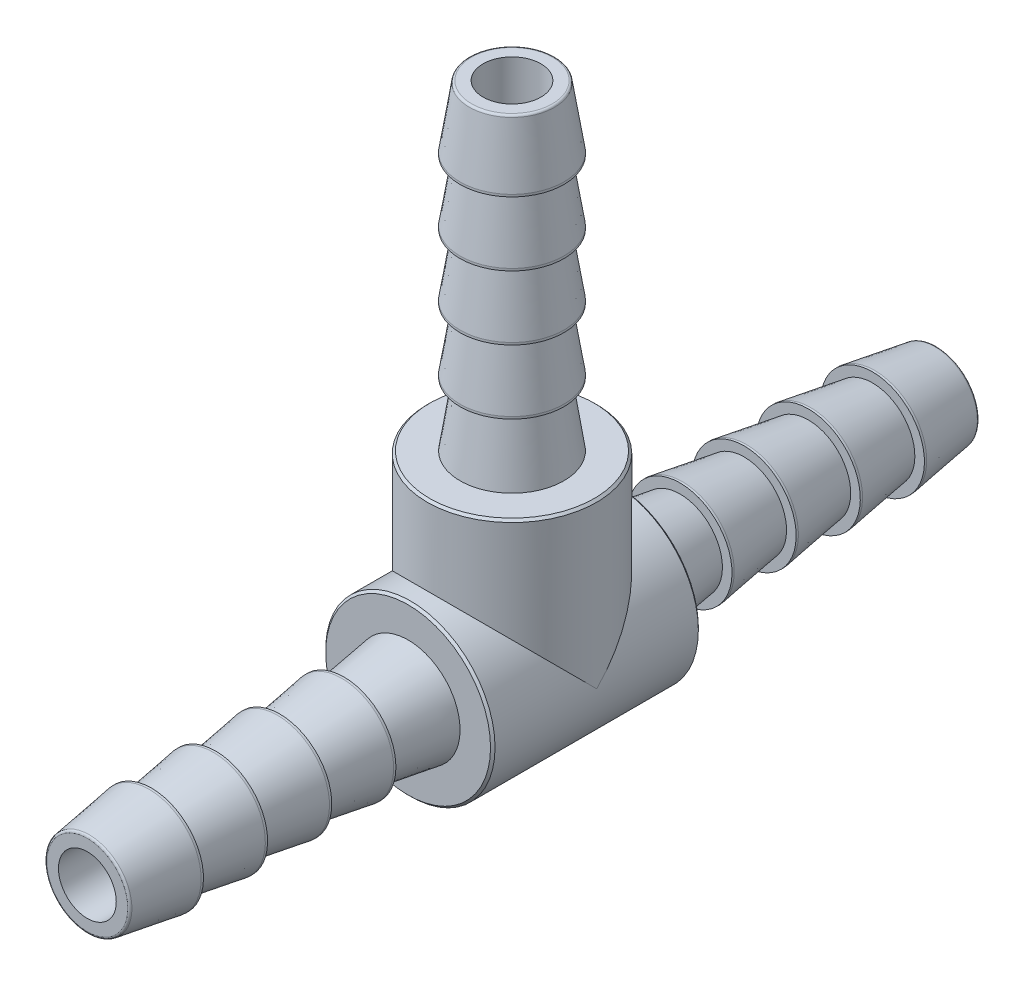
from build123d import *

# Parameters (mm, degrees)
SKETCH2_W       = 47.752
SKETCH2_H       = 4.7625
LPATTERN1_COUNT = 4
LPATTERN1_PITCH = 3.6068
SKETCH6_W       = 4.7625
SKETCH6_H       = 27.2415
LPATTERN2_COUNT = 4
LPATTERN2_PITCH = 3.6068
SKETCH9_W       = 1.6256
SKETCH9_H       = 27.2415
CHAMFER1_SIZE   = 0.127
FILLET1_R       = 0.127


with BuildPart() as part:
    # Sketch2 → Revolve1 (revolve)
    with BuildSketch(Plane(origin=(0, 0, 0), x_dir=(0, 0, -1), z_dir=(1, 0, 0)), mode=Mode.PRIVATE) as revolve1_sk:
        with Locations((0, 2.38125)):
            Rectangle(SKETCH2_W, SKETCH2_H)
    revolve(revolve1_sk.sketch.rotate(Axis((0, 0, 23.876), (0, 0, -1)), 90), axis=Axis((0, 0, 23.876), (0, 0, -1)))

    # Sketch3 → Cut-Revolve1 (revolve, cut)
    with BuildSketch(Plane(origin=(0, 0, 0), x_dir=(0, 0, -1), z_dir=(1, 0, 0)), mode=Mode.PRIVATE) as cut_revolve1_sk:
        Polygon((-23.876, 4.7625), (-23.876, 2.38125), (-9.4488, 2.38125), (-5.842, 2.921), (-5.842, 4.7625), align=None)
    cut_revolve1 = revolve(cut_revolve1_sk.sketch.rotate(Axis((0, 0, 23.876), (0, 0, -1)), 90), axis=Axis((0, 0, 23.876), (0, 0, -1)), mode=Mode.SUBTRACT)

    # Sketch4 → Revolve2 (revolve)
    with BuildSketch(Plane(origin=(0, 0, 0), x_dir=(0, 0, -1), z_dir=(1, 0, 0))):
        Polygon((-20.2692, 2.921), (-20.3962, 2.921), (-23.876, 2.38125), (-20.2692, 2.38125), align=None)
    revolve2 = revolve(axis=Axis((0, 0, 5.842), (0, 0, 1)))

    # LPattern1: Revolve2 ×4
    with Locations(*[(0, 0, -i * LPATTERN1_PITCH) for i in range(1, LPATTERN1_COUNT)]):
        add(revolve2)

    # Mirror1: Cut-Revolve1, Revolve2 across plane
    add(cut_revolve1.mirror(Plane.XY), mode=Mode.SUBTRACT)
    add(revolve2.mirror(Plane.XY))

    # Mirror1 copy 1 sketch → Mirror1 copy 1 (revolve)
    with BuildSketch(Plane(origin=(0, 0, 3.6068), x_dir=(0, 0, 1), z_dir=(1, 0, 0))):
        Polygon((-20.2692, -2.921), (-20.3962, -2.921), (-23.876, -2.38125), (-20.2692, -2.38125), align=None)
    revolve(axis=Axis((0, 0, -2.2352), (0, 0, 1)))

    # Mirror1 copy 2 sketch → Mirror1 copy 2 (revolve)
    with BuildSketch(Plane(origin=(0, 0, 7.2136), x_dir=(0, 0, 1), z_dir=(1, 0, 0))):
        Polygon((-20.2692, -2.921), (-20.3962, -2.921), (-23.876, -2.38125), (-20.2692, -2.38125), align=None)
    revolve(axis=Axis((0, 0, 1.3716), (0, 0, 1)))

    # Mirror1 copy 3 sketch → Mirror1 copy 3 (revolve)
    with BuildSketch(Plane(origin=(0, 0, 10.8204), x_dir=(0, 0, 1), z_dir=(1, 0, 0))):
        Polygon((-20.2692, -2.921), (-20.3962, -2.921), (-23.876, -2.38125), (-20.2692, -2.38125), align=None)
    revolve(axis=Axis((0, 0, 4.9784), (0, 0, 1)))

    # Sketch6 → Revolve3 (revolve)
    with BuildSketch(Plane(origin=(0, 0, 0), x_dir=(0, 0, -1), z_dir=(1, 0, 0)), mode=Mode.PRIVATE) as revolve3_sk:
        with Locations((-2.38125, 13.62075)):
            Rectangle(SKETCH6_W, SKETCH6_H)
    revolve(revolve3_sk.sketch.rotate(Axis((0, 0, 0), (0, 1, 0)), 180), axis=Axis((0, 0, 0), (0, 1, 0)))

    # Sketch7 → Cut-Revolve3 (revolve, cut)
    with BuildSketch(Plane(origin=(0, 0, 0), x_dir=(0, 0, -1), z_dir=(1, 0, 0)), mode=Mode.PRIVATE) as cut_revolve3_sk:
        Polygon((-2.921, 9.2075), (-2.38125, 12.8143), (-2.38125, 27.2415), (-4.7625, 27.2415), (-4.7625, 9.2075), align=None)
    revolve(cut_revolve3_sk.sketch.rotate(Axis((0, 0, 0), (0, 1, 0)), 180), axis=Axis((0, 0, 0), (0, 1, 0)), mode=Mode.SUBTRACT)

    # Sketch8 → Revolve4 (revolve)
    with BuildSketch(Plane(origin=(0, 0, 0), x_dir=(0, 0, -1), z_dir=(1, 0, 0)), mode=Mode.PRIVATE) as revolve4_sk:
        Polygon((-2.38125, 27.2415), (-2.921, 23.7617), (-2.921, 23.6347), (-2.38125, 23.6347), align=None)
    revolve4 = revolve(revolve4_sk.sketch.rotate(Axis((0, 27.2415, 0), (0, -1, 0)), 180), axis=Axis((0, 27.2415, 0), (0, -1, 0)))

    # LPattern2: Revolve4 ×4
    with Locations(*[(0, -i * LPATTERN2_PITCH, 0) for i in range(1, LPATTERN2_COUNT)]):
        add(revolve4)

    # Sketch5 → Cut-Revolve2 (revolve, cut)
    with BuildSketch(Plane(origin=(0, 0, 0), x_dir=(0, 0, -1), z_dir=(1, 0, 0))):
        with BuildLine():
            Line((-23.876, 1.6256), (0, 1.6256))
            ThreePointArc((0, 1.6256), (1.149472783, 1.149472783), (1.6256, 0))
            Line((1.6256, 0), (-23.876, 0))
            Line((-23.876, 0), (-23.876, 1.6256))
        make_face()
    revolve(axis=Axis((0, 0, 23.876), (0, 0, -1)), mode=Mode.SUBTRACT)

    # Sketch9 → Cut-Revolve4 (revolve, cut)
    with BuildSketch(Plane(origin=(0, 0, 0), x_dir=(0, 0, -1), z_dir=(1, 0, 0))):
        with Locations((-0.8128, 13.62075)):
            Rectangle(SKETCH9_W, SKETCH9_H)
    revolve(axis=Axis((0, 27.2415, 0), (0, -1, 0)), mode=Mode.SUBTRACT)

    # Chamfer1
    chamfer1_edges = [part.edges().sort_by_distance(p)[0] for p in [
        (-4.7625, 0, -5.842),
        (0, 9.2075, 4.7625),
        (-4.7625, 0, 5.842),
    ]]
    chamfer(chamfer1_edges, length=CHAMFER1_SIZE)

    # Fillet1
    fillet1_edges = [part.edges().sort_by_distance(p)[0] for p in [
        (0, -2.38125, 23.876),
        (0, -2.38125, -23.876),
        (0, 27.2415, 2.38125),
    ]]
    fillet(fillet1_edges, radius=FILLET1_R)


solid = part.part
